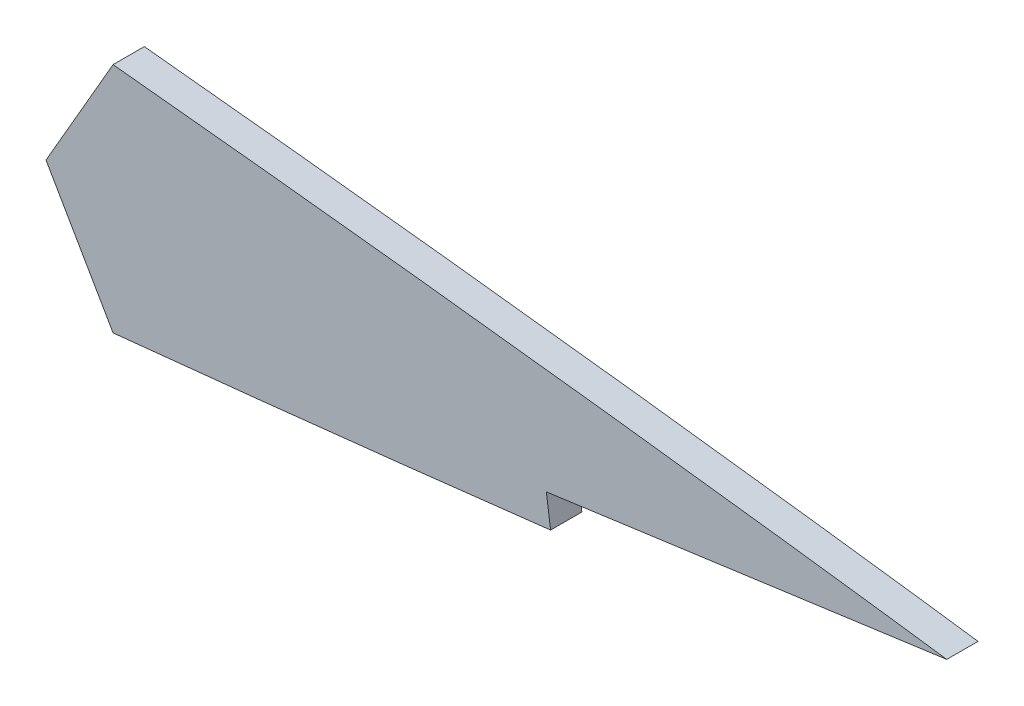
from build123d import *

# Parameters (mm, degrees)
BOSS_EXTRUDE1_DEPTH = 3.175
CUT_EXTRUDE1_DEPTH  = 5.08


with BuildPart() as part:
    # Sketch2 → Boss-Extrude1 (new body)
    with BuildSketch(Plane.XY):
        with BuildLine():
            add(Edge.make_bspline(
                [(349.25, 0), (349.081845346, 0.195028946), (348.546486748, 0.815947966), (346.670763268, 0.635287815), (344.11086643, 1.231330826), (340.348873806, 1.640765335), (335.631665172, 2.319189902), (329.896669995, 3.064968776), (323.213152208, 3.937751592), (315.610665982, 4.899637326), (307.139892382, 5.94572983), (297.851820227, 7.058039906), (287.804163994, 8.223966301), (277.05860736, 9.42727111), (265.681494766, 10.653371923), (253.743033604, 11.887008331), (241.316804275, 13.11226643), (228.479451099, 14.31194461), (215.310032455, 15.470294327), (201.889886046, 16.567949836), (188.301472832, 17.587013879), (174.628693344, 18.508566703), (160.95579103, 19.313339436), (147.366939387, 19.981000511), (133.946062727, 20.493746123), (120.775518049, 20.834848585), (107.936696619, 20.987647162), (95.508487727, 20.940015693), (83.567514363, 20.682753776), (72.187279219, 20.209340103), (61.437827927, 19.518536296), (51.385233466, 18.612420938), (42.090988888, 17.498070831), (33.611817078, 16.184967443), (25.998868366, 14.686825017), (19.297496021, 13.02058345), (13.543519177, 11.202490675), (8.772941595, 9.249479701), (4.98137124, 7.174763565), (2.229693173, 4.974247418), (0.364862544, 2.594695774), (0.115985535, 0.824823436), (0, 0)],
                knots=[0, 0, 0, 0, 0.002091853, 0.006659889, 0.014240034, 0.024784942, 0.038226646, 0.054481348, 0.073444809, 0.094998776, 0.11900639, 0.145318898, 0.173770288, 0.204183654, 0.236370679, 0.270129473, 0.305250351, 0.341516861, 0.378701149, 0.416575318, 0.454902219, 0.493447217, 0.531971459, 0.57023708, 0.608012632, 0.645066312, 0.681178002, 0.716129843, 0.74971807, 0.781748295, 0.812036536, 0.840415327, 0.866732056, 0.890849065, 0.912651845, 0.932046273, 0.94897292, 0.963413199, 0.975421325, 0.985175212, 0.993091122, 1, 1, 1, 1], degree=3))
            add(Edge.make_bspline(
                [(349.25, 0), (349.081845346, -0.195028946), (348.546486748, -0.815947966), (346.670763268, -0.635287815), (344.11086643, -1.231330826), (340.348873806, -1.640765335), (335.631665172, -2.319189902), (329.896669995, -3.064968776), (323.213152208, -3.937751592), (315.610665982, -4.899637326), (307.139892382, -5.94572983), (297.851820227, -7.058039906), (287.804163994, -8.223966301), (277.05860736, -9.42727111), (265.681494766, -10.653371923), (253.743033604, -11.887008331), (241.316804275, -13.11226643), (228.479451099, -14.31194461), (215.310032455, -15.470294327), (201.889886046, -16.567949836), (188.301472832, -17.587013879), (174.628693344, -18.508566703), (160.95579103, -19.313339436), (147.366939387, -19.981000511), (133.946062727, -20.493746123), (120.775518049, -20.834848585), (107.936696619, -20.987647162), (95.508487727, -20.940015693), (83.567514363, -20.682753776), (72.187279219, -20.209340103), (61.437827927, -19.518536296), (51.385233466, -18.612420938), (42.090988888, -17.498070831), (33.611817078, -16.184967443), (25.998868366, -14.686825017), (19.297496021, -13.02058345), (13.543519177, -11.202490675), (8.772941595, -9.249479701), (4.98137124, -7.174763565), (2.229693173, -4.974247418), (0.364862544, -2.594695774), (0.115985535, -0.824823436), (0, 0)],
                knots=[0, 0, 0, 0, 0.002091853, 0.006659889, 0.014240034, 0.024784942, 0.038226646, 0.054481348, 0.073444809, 0.094998776, 0.11900639, 0.145318898, 0.173770288, 0.204183654, 0.236370679, 0.270129473, 0.305250351, 0.341516861, 0.378701149, 0.416575318, 0.454902219, 0.493447217, 0.531971459, 0.57023708, 0.608012632, 0.645066312, 0.681178002, 0.716129843, 0.74971807, 0.781748295, 0.812036536, 0.840415327, 0.866732056, 0.890849065, 0.912651845, 0.932046273, 0.94897292, 0.963413199, 0.975421325, 0.985175212, 0.993091122, 1, 1, 1, 1], degree=3))
        make_face()
    extrude(amount=BOSS_EXTRUDE1_DEPTH)

    # Sketch3 → Cut-Extrude1 (cut)
    with BuildSketch(Plane.XY.offset(3.175)):
        Polygon((247.65, 50.8), (0, 50.8), (0, 0), (0, -50.8), (247.65, -50.8), (254.465257243, -11.804371811), (247.65, 0), (254.465257243, 11.804371811), align=None)
        Polygon((299.357110071, -10.070757643), (349.68283748, -3.145357963), (348.81716252, 3.145357963), (298.491435111, -3.780041717), align=None)
    extrude(amount=-CUT_EXTRUDE1_DEPTH, mode=Mode.SUBTRACT)


solid = part.part
